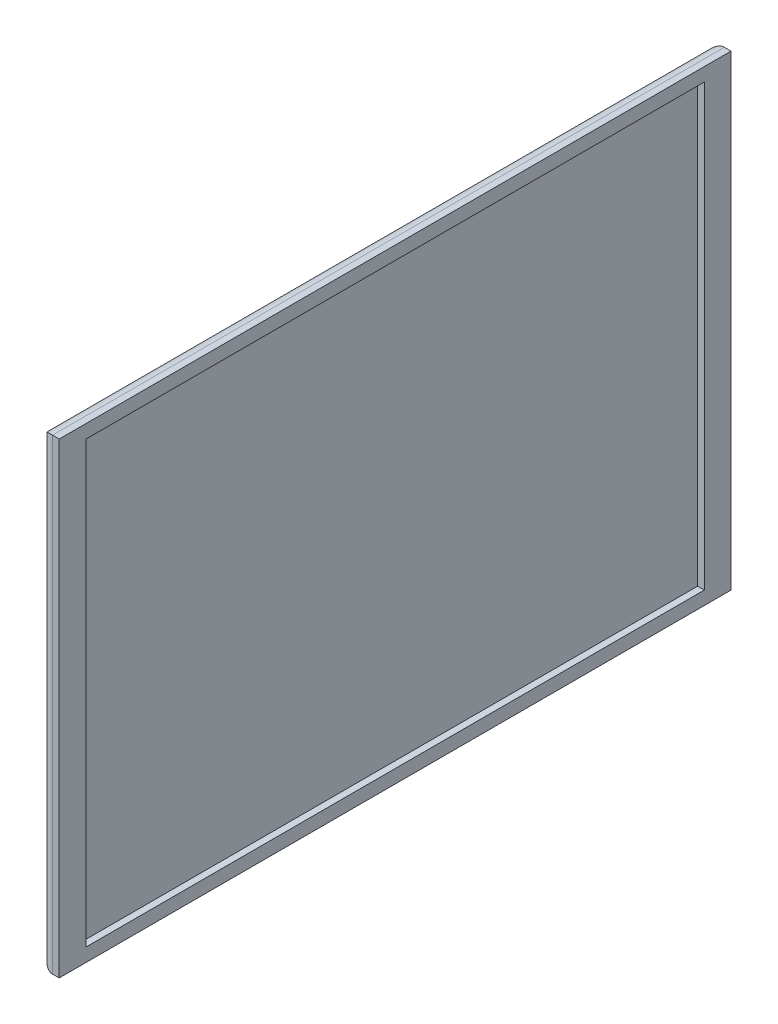
from build123d import *

# Parameters (mm, degrees)
SKETCH1_W           = 25.06
SKETCH1_H           = 17.41
BOSS_EXTRUDE1_DEPTH = 0.75
FILLET4_R           = 0.5
SKETCH2_W           = 23.06
SKETCH2_H           = 16.41
CUT_EXTRUDE1_DEPTH  = 0.25
SCALE1_SCALE        = 10


with BuildPart() as part:
    # Sketch1 → Boss-Extrude1 (new body)
    with BuildSketch(Plane(origin=(0, 0, 0), x_dir=(0, 0, -1), z_dir=(1, 0, 0))):
        Rectangle(SKETCH1_W, SKETCH1_H)
    extrude(amount=BOSS_EXTRUDE1_DEPTH)

    # Fillet4
    fillet4_edges = [part.edges().sort_by_distance(p)[0] for p in [
        (0, -8.705, 0),
        (0, 0, 12.53),
        (0, 8.705, 0),
        (0, 0, -12.53),
    ]]
    fillet(fillet4_edges, radius=FILLET4_R)

    # Sketch2 → Cut-Extrude1 (cut)
    with BuildSketch(Plane(origin=(0.75, 0, 0), x_dir=(0, 0, -1), z_dir=(1, 0, 0))):
        Rectangle(SKETCH2_W, SKETCH2_H)
    extrude(amount=-CUT_EXTRUDE1_DEPTH, mode=Mode.SUBTRACT)


with BuildPart() as part_1:
    # Scale1: scaled about (0.276512494, 0, 0)
    add(part.part.scale(SCALE1_SCALE).moved(Location((-2.488612446, 0, 0))))


solid = part_1.part
